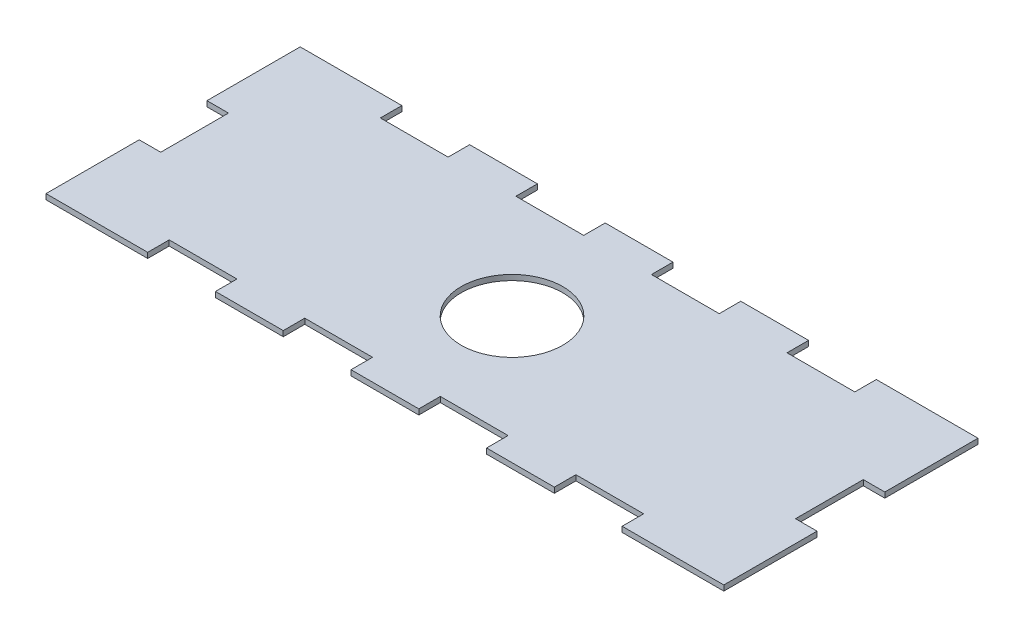
from build123d import *

# Parameters (mm, degrees)
SKETCH1_R           = 15
BOSS_EXTRUDE1_DEPTH = 1.5875


with BuildPart() as part:
    # Sketch1 → Boss-Extrude1 (new body)
    with BuildSketch(Plane(origin=(0, 0, 0), x_dir=(1, 0, 0), z_dir=(0, 1, 0))):
        Polygon((0, 27.5), (0, 0), (30, 0), (30, 6.35), (50, 6.35), (50, 0), (70, 0), (70, 6.35), (90, 6.35), (90, 0), (110, 0), (110, 6.35), (130, 6.35), (130, 0), (150, 0), (150, 6.35), (170, 6.35), (170, 0), (200, 0), (200, 27.5), (193.65, 27.5), (193.65, 47.5), (200, 47.5), (200, 75), (170, 75), (170, 68.65), (150, 68.65), (150, 75), (130, 75), (130, 68.65), (110, 68.65), (110, 75), (90, 75), (90, 68.65), (70, 68.65), (70, 75), (50, 75), (50, 68.65), (30, 68.65), (30, 75), (0, 75), (0, 47.5), (6.35, 47.5), (6.35, 27.5), align=None)
        with Locations((100, 37.5)):
            Circle(SKETCH1_R, mode=Mode.SUBTRACT)
    extrude(amount=BOSS_EXTRUDE1_DEPTH)


solid = part.part
